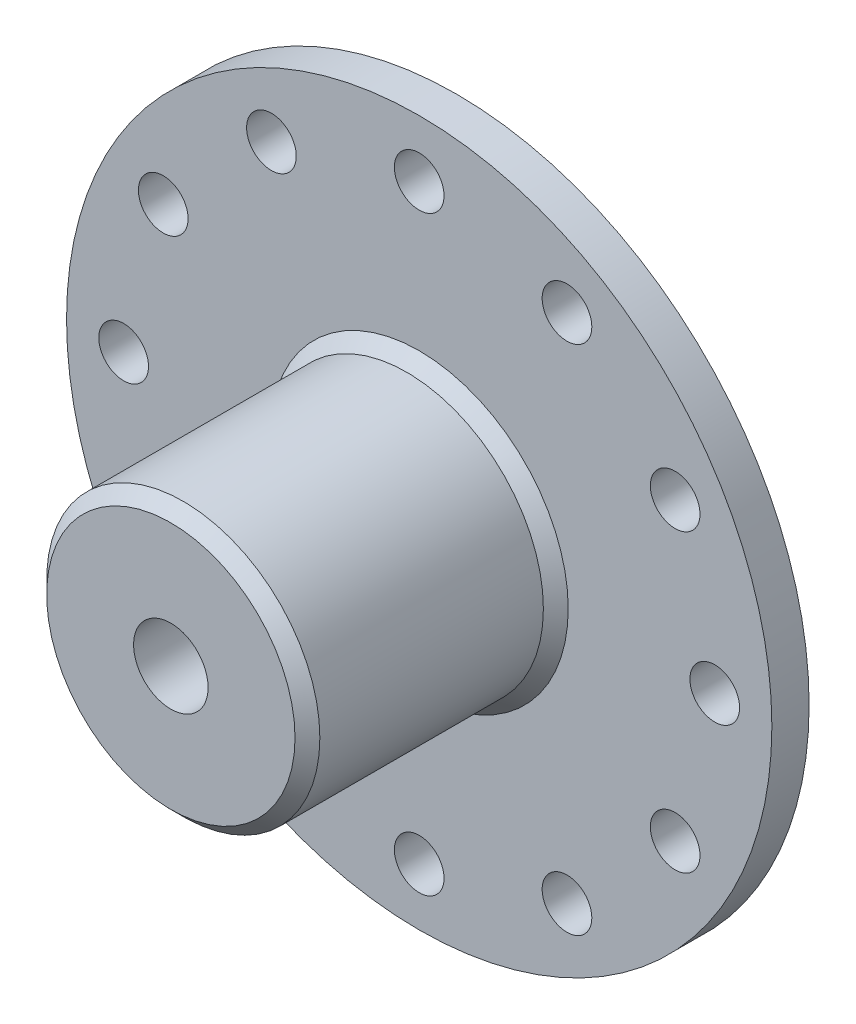
from build123d import *

# Parameters (mm, degrees)
SKETCH1_R           = 28.4
BOSS_EXTRUDE1_DEPTH = 3
SKETCH2_R           = 11
BOSS_EXTRUDE2_DEPTH = 20
SKETCH3_R           = 3
CUT_EXTRUDE1_DEPTH  = 24
SKETCH4_R           = 2
CUT_EXTRUDE2_DEPTH  = 15
CHAMFER1_SIZE       = 1
SKETCH5_R           = 2
CUT_EXTRUDE5_DEPTH  = 4.0000001
CIRPATTERN2_COUNT   = 12


with BuildPart() as part:
    # Sketch1 → Boss-Extrude1 (new body)
    with BuildSketch(Plane.XY):
        Circle(SKETCH1_R)
    extrude(amount=BOSS_EXTRUDE1_DEPTH)

    # Sketch2 → Boss-Extrude2 (add)
    with BuildSketch(Plane.XY.offset(3)):
        Circle(SKETCH2_R)
    extrude(amount=BOSS_EXTRUDE2_DEPTH)

    # Sketch3 → Cut-Extrude1 (cut, through all)
    with BuildSketch(Plane.XY.offset(23)):
        Circle(SKETCH3_R)
    extrude(amount=-CUT_EXTRUDE1_DEPTH, mode=Mode.SUBTRACT)

    # Sketch4 → Cut-Extrude2 (cut)
    with BuildSketch(Plane(origin=(0, 0, 0), x_dir=(1, 0, 0), z_dir=(0, 1, 0))):
        with Locations((0, -15)):
            Circle(SKETCH4_R)
    extrude(amount=-CUT_EXTRUDE2_DEPTH, mode=Mode.SUBTRACT)

    # Chamfer1
    chamfer1_edges = [part.edges().sort_by_distance(p)[0] for p in [
        (-11, 0, 3),
        (-11, 0, 23),
    ]]
    chamfer(chamfer1_edges, length=CHAMFER1_SIZE)

    # Sketch5 → Cut-Extrude5 (cut, through all)
    with BuildSketch(Plane.XY.offset(3)):
        with Locations((11.9, 20.61140461)):
            Circle(SKETCH5_R)
    cut_extrude5 = extrude(amount=-CUT_EXTRUDE5_DEPTH, mode=Mode.SUBTRACT)

    # CirPattern2: Cut-Extrude5 ×12 about axis
    cirpattern2_axis = Axis((0, 0, 0), (0, 0, 1))
    for i in range(1, CIRPATTERN2_COUNT):
        add(cut_extrude5.rotate(cirpattern2_axis, i * 360 / CIRPATTERN2_COUNT), mode=Mode.SUBTRACT)


solid = part.part
